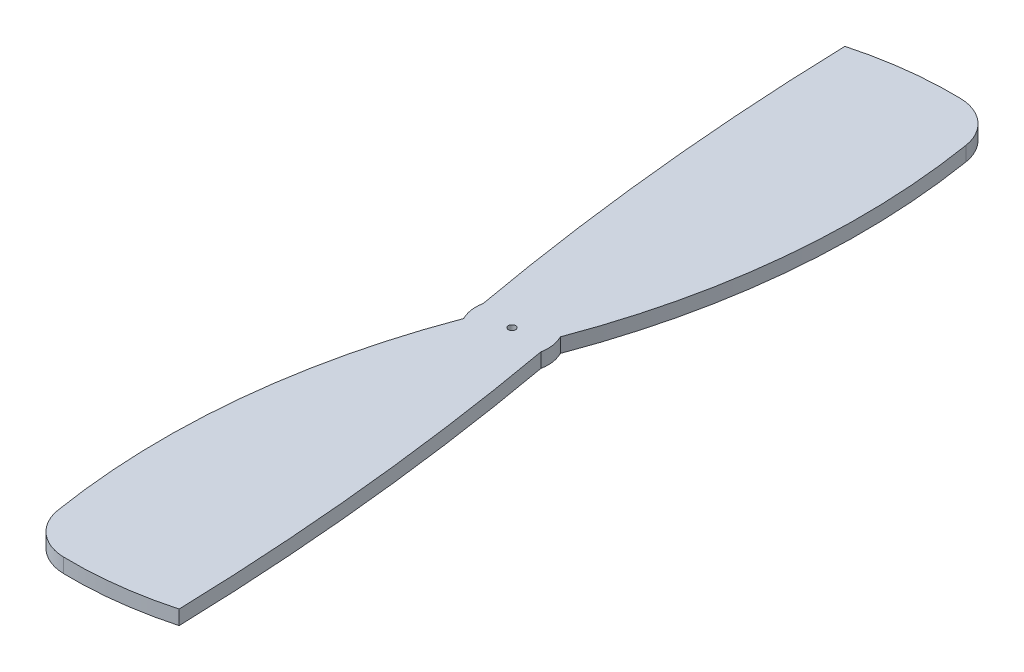
from build123d import *

# Parameters (mm, degrees)
SKETCH1_R           = 0.2
BOSS_EXTRUDE1_DEPTH = 0.8


with BuildPart() as part:
    # Sketch1 → Boss-Extrude1 (new body)
    with BuildSketch(Plane(origin=(0, 0, 0), x_dir=(1, 0, 0), z_dir=(0, 1, 0))):
        with BuildLine():
            ThreePointArc((-2.383636789, 23.134738828), (-2.370326041, 23.784413457), (-2.565996752, 24.404064385))
            ThreePointArc((-2.565996752, 24.404064385), (-0.19892847, 34.515692649), (-0.514652369, 44.895883246))
            ThreePointArc((-0.514652369, 44.895883246), (-1.342299158, 46.382879838), (-2.929984682, 46.995589192))
            ThreePointArc((-2.929984682, 46.995589192), (-5.811012003, 46.848007958), (-8.640837363, 46.287484025))
            ThreePointArc((-8.640837363, 46.287484025), (-7.900405237, 35.032644788), (-6.316363211, 23.865261172))
            ThreePointArc((-6.316363211, 23.865261172), (-6.329673959, 23.215586543), (-6.134003248, 22.595935615))
            ThreePointArc((-6.134003248, 22.595935615), (-8.50107153, 12.484307351), (-8.185347631, 2.104116754))
            ThreePointArc((-8.185347631, 2.104116754), (-7.357700842, 0.617120162), (-5.770015318, 0.004410808))
            ThreePointArc((-5.770015318, 0.004410808), (-2.888987997, 0.151992042), (-0.059162637, 0.712515975))
            ThreePointArc((-0.059162637, 0.712515975), (-0.799594763, 11.967355212), (-2.383636789, 23.134738828))
        make_face()
        with Locations((-4.35, 23.5)):
            Circle(SKETCH1_R, mode=Mode.SUBTRACT)
    extrude(amount=BOSS_EXTRUDE1_DEPTH)


solid = part.part
